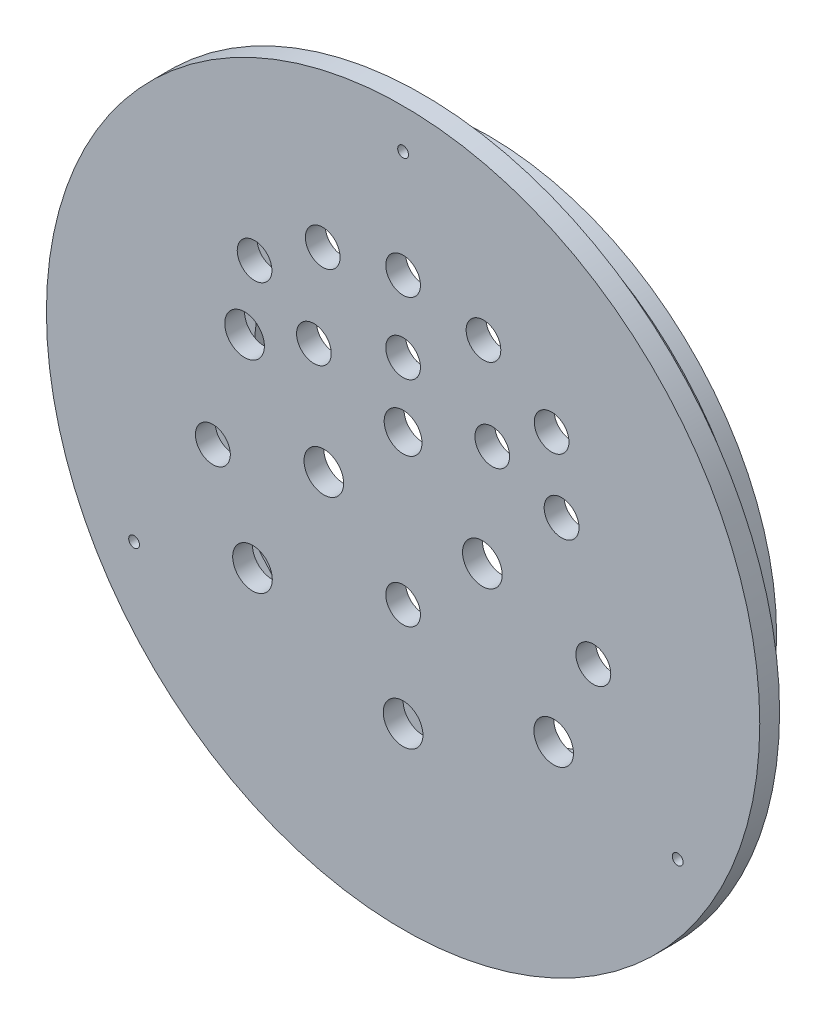
from build123d import *

# Parameters (mm, degrees)
SKETCH1_R                  = 114.3
EXTRUDE1_DEPTH             = 6.35
SKETCH2_R                  = 93.6625
EXTRUDE2_DEPTH             = 15.875
SKETCH3_R                  = 87.3125
CUT_EXTRUDE1_DEPTH         = 15.875
SKETCH4_W                  = 3.175
SKETCH4_H                  = 2.54
CHAMFER1_SIZE              = 1.27
CHAMFER2_SIZE              = 0.635
SKETCH9_R                  = 6.35
CUT_EXTRUDE2_DEPTH         = 23.225
SKETCH11_R                 = 5.55625
CUT_EXTRUDE4_DEPTH         = 23.225
SKETCH12_R                 = 6.35
CUT_EXTRUDE5_DEPTH         = 23.225
SKETCH13_R                 = 5.55625
CUT_EXTRUDE6_DEPTH         = 23.225
SKETCH17_R                 = 92.3925
SKETCH17_R_2               = 69.85
BOSS_EXTRUDE1_DEPTH        = 5.08
F_12_24_TAPPED_HOLE1_D     = 4.4958
F_12_24_TAPPED_HOLE1_DEPTH = 14.224
F_8_32_TAPPED_HOLE1_D      = 3.4544
F_8_32_TAPPED_HOLE1_DEPTH  = 10.668
SKETCH25_R                 = 5.588
CUT_EXTRUDE8_DEPTH         = 28.305
SKETCH24_R                 = 6.35
CUT_EXTRUDE7_DEPTH         = 7.35
SKETCH26_R                 = 5.588
CUT_EXTRUDE9_DEPTH         = 28.305
SKETCH27_R                 = 5.55625
CUT_EXTRUDE10_DEPTH        = 28.305
SKETCH28_R                 = 6.062568313
CUT_EXTRUDE11_DEPTH        = 28.305


with BuildPart() as part:
    # Sketch1 → Extrude1 (new body)
    with BuildSketch(Plane.XY):
        Circle(SKETCH1_R)
    extrude(amount=EXTRUDE1_DEPTH)

    # Sketch2 → Extrude2 (add)
    with BuildSketch(Plane(origin=(0, 0, 0), x_dir=(-1, 0, 0), z_dir=(0, 0, -1))):
        Circle(SKETCH2_R)
    extrude(amount=EXTRUDE2_DEPTH)

    # Sketch3 → Cut-Extrude1 (cut)
    with BuildSketch(Plane(origin=(0, 0, -15.875), x_dir=(-1, 0, 0), z_dir=(0, 0, -1))):
        Circle(SKETCH3_R)
    extrude(amount=-CUT_EXTRUDE1_DEPTH, mode=Mode.SUBTRACT)

    # Sketch4 → Cut-Revolve1 (revolve, cut)
    with BuildSketch(Plane(origin=(0, 0, 0), x_dir=(0, 0, -1), z_dir=(1, 0, 0))):
        with Locations((4.395911794, 92.3925)):
            Rectangle(SKETCH4_W, SKETCH4_H)
        with Locations((10.251990741, 92.3925)):
            Rectangle(SKETCH4_W, SKETCH4_H)
    revolve(axis=Axis((0, 0, 0), (0, 0, -1)), mode=Mode.SUBTRACT)

    # Chamfer1
    chamfer1_edges = [part.edges().sort_by_distance(p)[0] for p in [
        (93.6625, 0, -15.875),
    ]]
    chamfer(chamfer1_edges, length=CHAMFER1_SIZE)

    # Chamfer2
    chamfer2_edges = [part.edges().sort_by_distance(p)[0] for p in [
        (93.6625, 0, -2.808411794),
        (93.6625, 0, -5.983411794),
        (93.6625, 0, -8.664490741),
        (93.6625, 0, -11.839490741),
    ]]
    chamfer(chamfer2_edges, length=CHAMFER2_SIZE)

    # Sketch9 → Cut-Extrude2 (cut, through all)
    with BuildSketch(Plane.XY.offset(6.35)):
        with Locations((-48.26, -38.1)):
            Circle(SKETCH9_R)
        with Locations((48.26, -38.1)):
            Circle(SKETCH9_R)
    extrude(amount=-CUT_EXTRUDE2_DEPTH, mode=Mode.SUBTRACT)

    # Sketch11 → Cut-Extrude4 (cut, through all)
    with BuildSketch(Plane.XY.offset(6.35)):
        with Locations((25.758421832, 62.186331333)):
            Circle(SKETCH11_R)
        with Locations((47.595357442, 47.595357442)):
            Circle(SKETCH11_R)
        with Locations((-47.595357442, 47.595357442)):
            Circle(SKETCH11_R)
        with Locations((-25.758421832, 62.186331333)):
            Circle(SKETCH11_R)
        with Locations((0, 67.31)):
            Circle(SKETCH11_R)
    extrude(amount=-CUT_EXTRUDE4_DEPTH, mode=Mode.SUBTRACT)

    # Sketch12 → Cut-Extrude5 (cut, through all)
    with BuildSketch(Plane.XY.offset(6.35)):
        with Locations((0, -57.15)):
            Circle(SKETCH12_R)
        with Locations((-25.4, 0)):
            Circle(SKETCH12_R)
        with Locations((25.4, 0)):
            Circle(SKETCH12_R)
    extrude(amount=-CUT_EXTRUDE5_DEPTH, mode=Mode.SUBTRACT)

    # Sketch13 → Cut-Extrude6 (cut, through all)
    with BuildSketch(Plane.XY.offset(6.35)):
        with Locations((0, 44.45)):
            Circle(SKETCH13_R)
        with Locations((28.571909251, 34.050675497)):
            Circle(SKETCH13_R)
        with Locations((-28.571909251, 34.050675497)):
            Circle(SKETCH13_R)
    extrude(amount=-CUT_EXTRUDE6_DEPTH, mode=Mode.SUBTRACT)

    # Sketch17 → Boss-Extrude1 (add)
    with BuildSketch(Plane(origin=(0, 0, -15.875), x_dir=(-1, 0, 0), z_dir=(0, 0, -1))):
        Circle(SKETCH17_R)
        Circle(SKETCH17_R_2, mode=Mode.SUBTRACT)
    extrude(amount=BOSS_EXTRUDE1_DEPTH)

    # #12-24 Tapped Hole1
    with Locations(Plane(origin=(0, 0, -20.955), x_dir=(-1, 0, 0), z_dir=(0, 0, -1))):
        with Locations((0, 79.375), (-79.375, 0), (0, -79.375), (79.375, 0)):
            Hole(F_12_24_TAPPED_HOLE1_D / 2, depth=F_12_24_TAPPED_HOLE1_DEPTH)

    # #8-32 Tapped Hole1
    with Locations(Plane.XY.offset(6.35)):
        with Locations((0, 101.6), (-86.20809861, -49.772268939), (87.988181024, -50.8)):
            Hole(F_8_32_TAPPED_HOLE1_D / 2, depth=F_8_32_TAPPED_HOLE1_DEPTH)

    # Sketch25 → Cut-Extrude8 (cut, through all)
    with BuildSketch(Plane.XY.offset(6.35)):
        with Locations((60.96, -10.16)):
            Circle(SKETCH25_R)
        with Locations((-60.96, -10.16)):
            Circle(SKETCH25_R)
    extrude(amount=-CUT_EXTRUDE8_DEPTH, mode=Mode.SUBTRACT)

    # Sketch24 → Cut-Extrude7 (cut, through all)
    with BuildSketch(Plane(origin=(0, 0, 0), x_dir=(-1, 0, 0), z_dir=(0, 0, -1))):
        with Locations((50.8, 25.4)):
            Circle(SKETCH24_R)
    extrude(amount=-CUT_EXTRUDE7_DEPTH, mode=Mode.SUBTRACT)

    # Sketch26 → Cut-Extrude9 (cut, through all)
    with BuildSketch(Plane.XY.offset(6.35)):
        with Locations((50.8, 25.4)):
            Circle(SKETCH26_R)
    extrude(amount=-CUT_EXTRUDE9_DEPTH, mode=Mode.SUBTRACT)

    # Sketch27 → Cut-Extrude10 (cut, through all)
    with BuildSketch(Plane.XY.offset(6.35)):
        with Locations((0, -24.13)):
            Circle(SKETCH27_R)
    extrude(amount=-CUT_EXTRUDE10_DEPTH, mode=Mode.SUBTRACT)

    # Sketch28 → Cut-Extrude11 (cut, through all)
    with BuildSketch(Plane.XY.offset(6.35)):
        with Locations((0, 23.787786302)):
            Circle(SKETCH28_R)
    extrude(amount=-CUT_EXTRUDE11_DEPTH, mode=Mode.SUBTRACT)


solid = part.part
